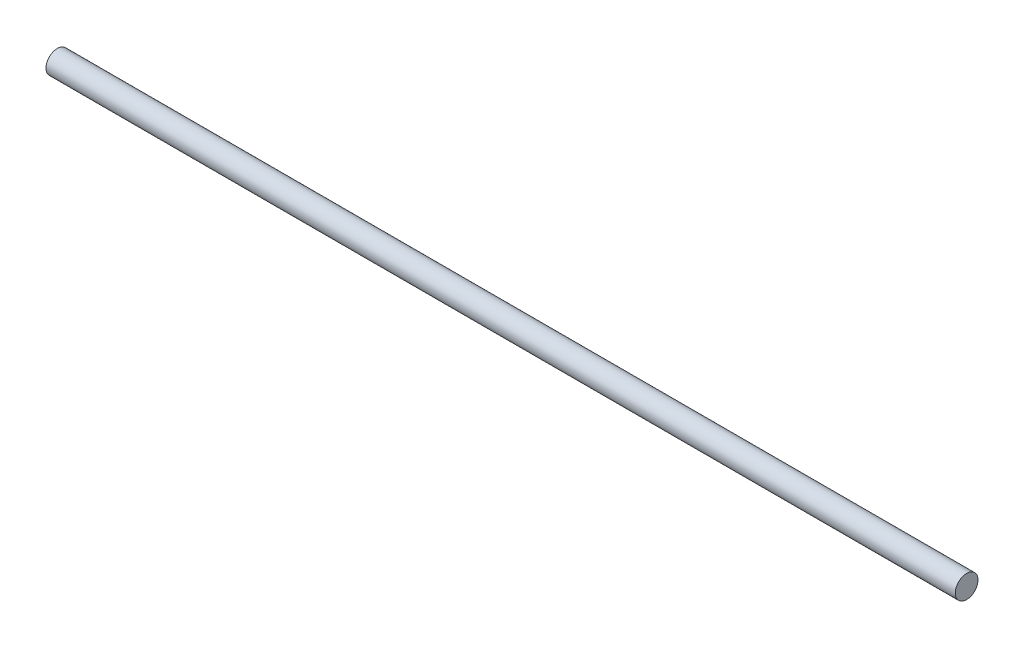
from build123d import *

# Parameters (mm, degrees)
SKETCH1_R           = 6.35
BOSS_EXTRUDE1_DEPTH = 508


with BuildPart() as part:
    # Sketch1 → Boss-Extrude1 (new body)
    with BuildSketch(Plane(origin=(0, 0, 0), x_dir=(0, 0, -1), z_dir=(1, 0, 0))):
        Circle(SKETCH1_R)
    extrude(amount=BOSS_EXTRUDE1_DEPTH)


solid = part.part
